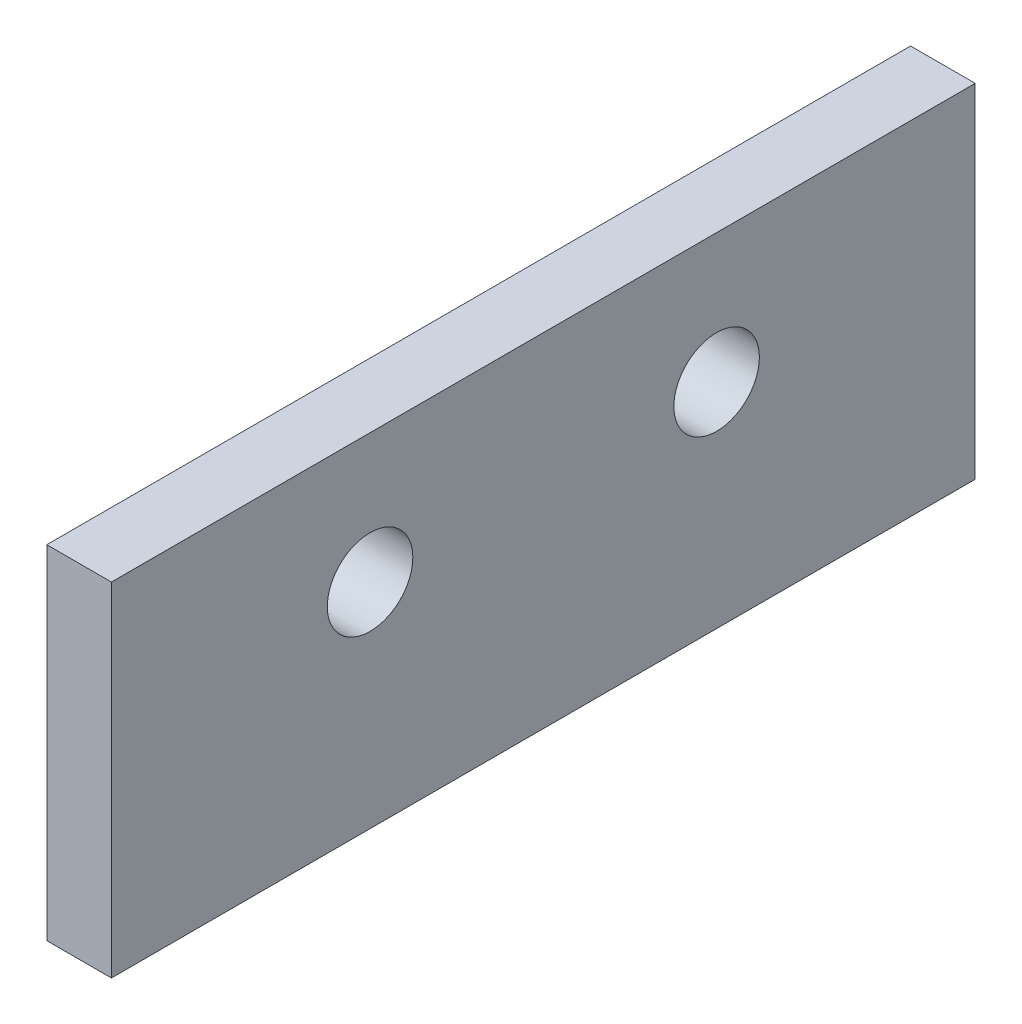
from build123d import *

# Parameters (mm, degrees)
SKETCH1_W           = 42.418
SKETCH1_H           = 16.8402
BOSS_EXTRUDE1_DEPTH = 3.175
SKETCH3_R           = 2.1
CUT_EXTRUDE1_DEPTH  = 4.175


with BuildPart() as part:
    # Sketch1 → Boss-Extrude1 (new body)
    with BuildSketch(Plane(origin=(0, 0, 0), x_dir=(0, 0, -1), z_dir=(1, 0, 0))):
        Rectangle(SKETCH1_W, SKETCH1_H)
    extrude(amount=BOSS_EXTRUDE1_DEPTH)

    # Sketch3 → Cut-Extrude1 (cut, through all)
    with BuildSketch(Plane(origin=(3.175, 0, 0), x_dir=(0, 0, -1), z_dir=(1, 0, 0))):
        with Locations((-8.509, 2.0701)):
            Circle(SKETCH3_R)
        with Locations((8.509, 2.0701)):
            Circle(SKETCH3_R)
    extrude(amount=-CUT_EXTRUDE1_DEPTH, mode=Mode.SUBTRACT)


solid = part.part
